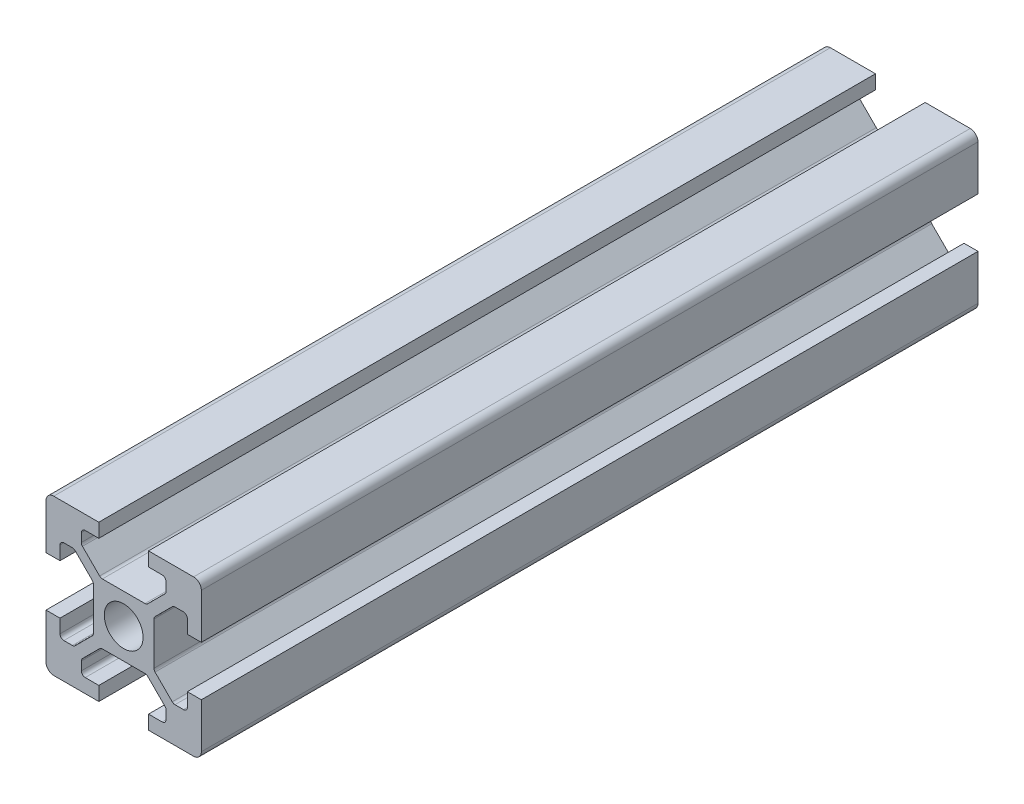
from build123d import *

# Parameters (mm, degrees)
SKETCH1_R           = 2.5
BOSS_EXTRUDE1_DEPTH = 100
FILLET1_R           = 1
FILLET2_R           = 0.5
FILLET3_R           = 0.5
FILLET4_R           = 0.5
FILLET5_R           = 0.5


with BuildPart() as part:
    # Sketch1 → Boss-Extrude1 (new body)
    with BuildSketch(Plane.XY):
        Polygon((13.2, 0), (13.2, 1.8), (15.45, 1.8), (15.45, 3.6), (12.95, 6.1), (7.05, 6.1), (4.55, 3.6), (4.55, 1.8), (6.8, 1.8), (6.8, 0), (0, 0), (0, 6.8), (1.8, 6.8), (1.8, 4.55), (3.6, 4.55), (6.1, 7.05), (6.1, 12.95), (3.6, 15.45), (1.8, 15.45), (1.8, 13.2), (0, 13.2), (0, 20), (6.8, 20), (6.8, 18.2), (4.55, 18.2), (4.55, 16.4), (7.05, 13.9), (12.95, 13.9), (15.45, 16.4), (15.45, 18.2), (13.2, 18.2), (13.2, 20), (20, 20), (20, 13.2), (18.2, 13.2), (18.2, 15.45), (16.4, 15.45), (13.9, 12.95), (13.9, 7.05), (16.4, 4.55), (18.2, 4.55), (18.2, 6.8), (20, 6.8), (20, 0), align=None)
        with Locations((10, 10)):
            Circle(SKETCH1_R, mode=Mode.SUBTRACT)
    extrude(amount=BOSS_EXTRUDE1_DEPTH)

    # Fillet1
    fillet1_edges = [part.edges().sort_by_distance(p)[0] for p in [
        (0, 0, 50),
        (0, 20, 50),
        (20, 20, 50),
        (20, 0, 50),
    ]]
    fillet(fillet1_edges, radius=FILLET1_R)

    # Fillet2
    fillet2_edges = [part.edges().sort_by_distance(p)[0] for p in [
        (4.55, 18.2, 50),
        (4.55, 16.4, 50),
        (7.05, 13.9, 50),
        (12.95, 13.9, 50),
        (15.45, 16.4, 50),
        (15.45, 18.2, 50),
    ]]
    fillet(fillet2_edges, radius=FILLET2_R)

    # Fillet3
    fillet3_edges = [part.edges().sort_by_distance(p)[0] for p in [
        (18.2, 15.45, 50),
        (16.4, 15.45, 50),
        (13.9, 12.95, 50),
        (13.9, 7.05, 50),
        (16.4, 4.55, 50),
        (18.2, 4.55, 50),
    ]]
    fillet(fillet3_edges, radius=FILLET3_R)

    # Fillet4
    fillet4_edges = [part.edges().sort_by_distance(p)[0] for p in [
        (1.8, 4.55, 50),
        (3.6, 4.55, 50),
        (6.1, 7.05, 50),
        (6.1, 12.95, 50),
        (3.6, 15.45, 50),
        (1.8, 15.45, 50),
    ]]
    fillet(fillet4_edges, radius=FILLET4_R)

    # Fillet5
    fillet5_edges = [part.edges().sort_by_distance(p)[0] for p in [
        (15.45, 1.8, 50),
        (15.45, 3.6, 50),
        (12.95, 6.1, 50),
        (7.05, 6.1, 50),
        (4.55, 3.6, 50),
        (4.55, 1.8, 50),
    ]]
    fillet(fillet5_edges, radius=FILLET5_R)


solid = part.part
